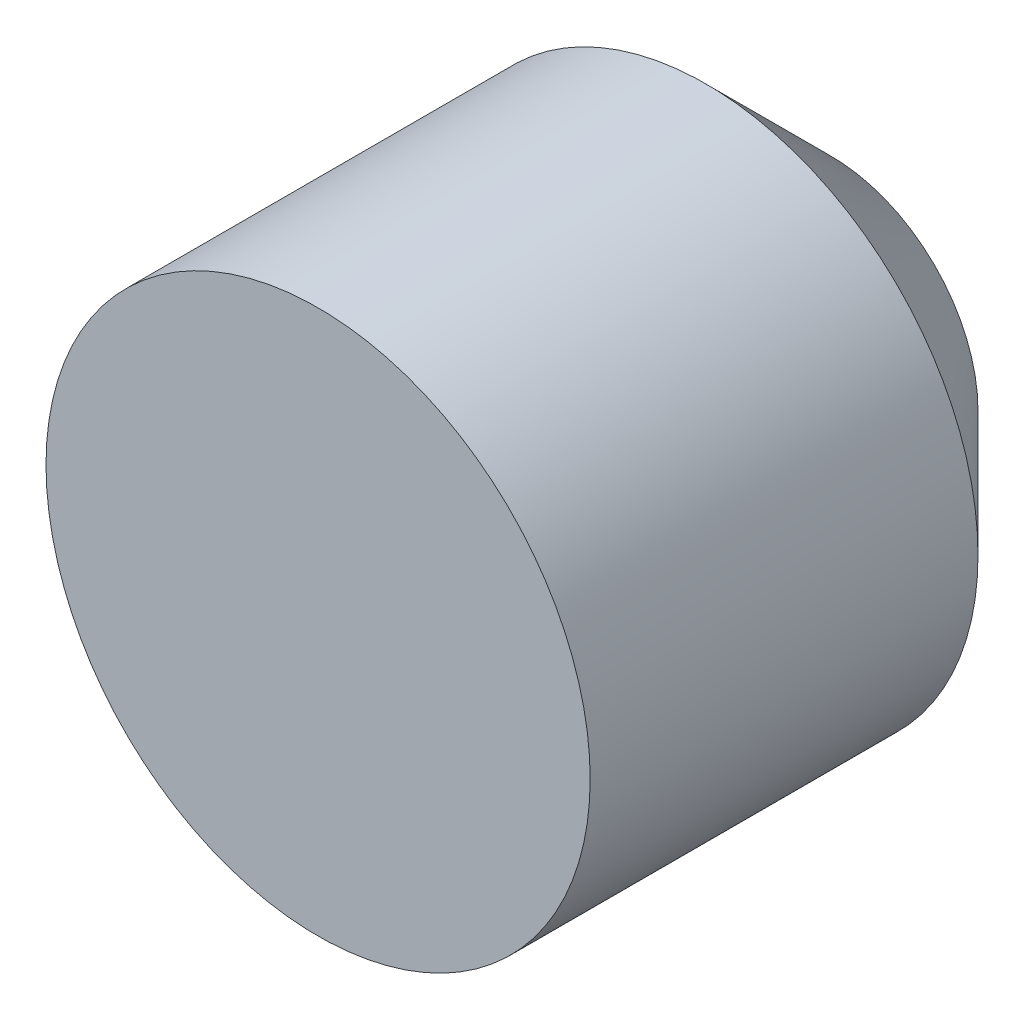
from build123d import *

# Parameters (mm, degrees)
SKETCH1_R           = 21.75
BOSS_EXTRUDE1_DEPTH = 41
CHAMFER1_SIZE       = 10


with BuildPart() as part:
    # Sketch1 → Boss-Extrude1 (new body)
    with BuildSketch(Plane.XY):
        Circle(SKETCH1_R)
    extrude(amount=BOSS_EXTRUDE1_DEPTH)

    # Chamfer1
    chamfer1_edges = [part.edges().sort_by_distance(p)[0] for p in [
        (-21.75, 0, 0),
    ]]
    chamfer(chamfer1_edges, length=CHAMFER1_SIZE)


solid = part.part
